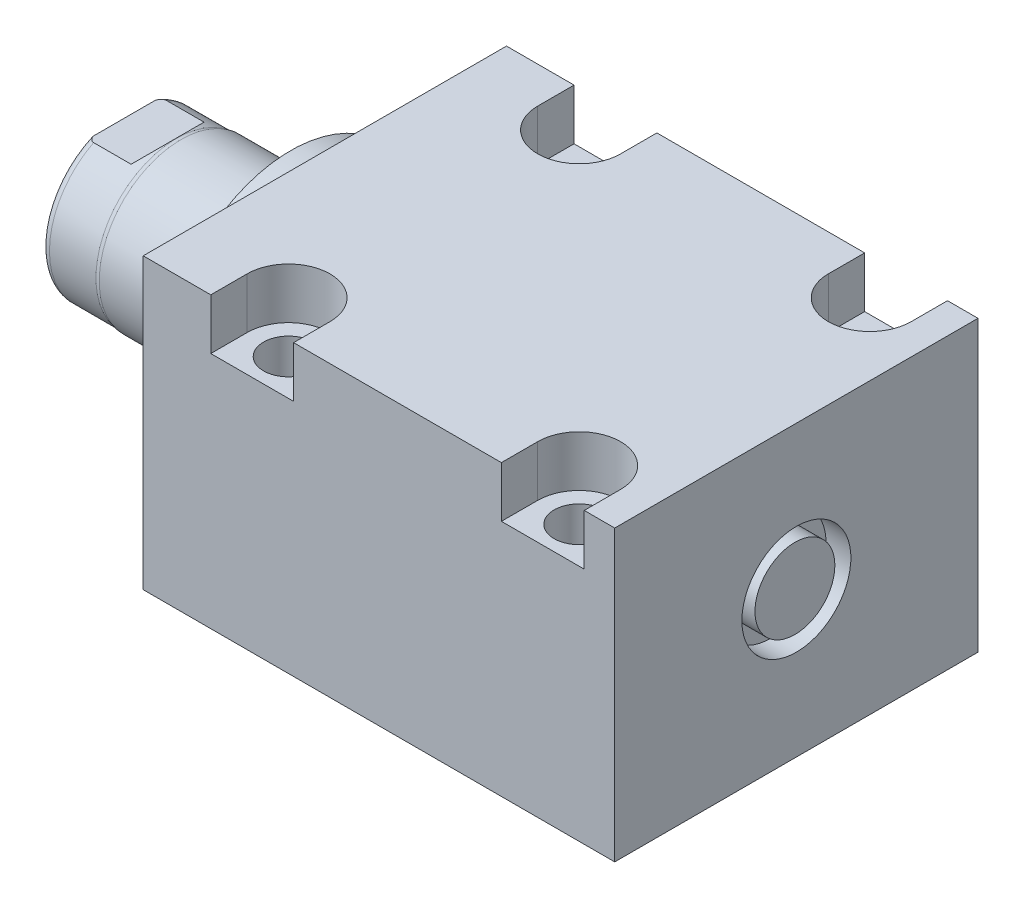
from build123d import *

# Parameters (mm, degrees)
SKETCH1_W          = 63.5
SKETCH1_H          = 50.546
EXTRUDE1_DEPTH     = 82.42
SKETCH5_R          = 22.225
EXTRUDE2_DEPTH     = 5.969
SKETCH6_W          = 14.2875
SKETCH6_H          = 29.091
CUT_EXTRUDE4_DEPTH = 30.48
HOLE2_D            = 8.7376
HOLE2_DEPTH        = 50.546
LPATTERN1_COUNT    = 2
LPATTERN1_PITCH    = 50.8
CUT_EXTRUDE5_DEPTH = 8.89
HOLE3_D            = 3.175
HOLE3_DEPTH        = 9.525
HOLE3_CBORE_D      = 11.3411
HOLE3_CBORE_DEPTH  = 1.4478
HOLE3_TIP          = 0.953866233
HOLE4_D            = 3.175
HOLE4_DEPTH        = 9.525
HOLE4_CBORE_D      = 11.3411
HOLE4_CBORE_DEPTH  = 1.4478
HOLE4_TIP          = 0.953866233
CHAMFER1_SIZE      = 0.635
SKETCH23_R         = 1.4478
LPATTERN3_COUNT    = 2
LPATTERN3_PITCH    = 50.8
SKETCH24_W         = 4.318
SKETCH24_H         = 9.525
SKETCH25_R         = 6.985
EXTRUDE3_DEPTH     = 4.064


with BuildPart() as part:
    # Sketch1 → Extrude1 (new body)
    with BuildSketch(Plane(origin=(0, 0, 0), x_dir=(0, 0, -1), z_dir=(1, 0, 0))):
        with Locations((0, -0.127)):
            Rectangle(SKETCH1_W, SKETCH1_H)
    extrude(amount=EXTRUDE1_DEPTH)

    # Sketch5 → Extrude2 (add)
    with BuildSketch(Plane.ZY):
        with Locations(Location((0, 0, 0), (0, 0, 180))):  # turned: the seam where the file's is
            Circle(SKETCH5_R)
    extrude(amount=EXTRUDE2_DEPTH)

    # Sketch6 → Revolve1 (revolve)
    with BuildSketch(Plane(origin=(0, 0, 0), x_dir=(0, 0, 1), z_dir=(0, -1, 0))):
        with Locations((-7.14375, 20.5145)):
            Rectangle(SKETCH6_W, SKETCH6_H)
    revolve(axis=Axis((5.754582971, 0, 0), (-1, 0, 0)))

    # S2D0001 → Cut-Revolve4 (revolve, cut)
    with BuildSketch(Plane(origin=(-18.511260017, 3.2639, 0), x_dir=(0, 1, 0), z_dir=(0, 0, 1)), mode=Mode.PRIVATE) as cut_revolve4_sk:
        Polygon((2.286, 14.481017728), (2.286, -1.942460017), (-3.2639, -1.942460017), (-3.2639, 16.548739983), (3.4798, 16.548739983), align=None)
    revolve(cut_revolve4_sk.sketch.rotate(Axis((0, 0, 0), (-1, 0, 0)), 90), axis=Axis((0, 0, 0), (-1, 0, 0)), mode=Mode.SUBTRACT)  # turned: the seam where the file's is

    # Sketch8 → Cut-Revolve5 (revolve, cut)
    with BuildSketch(Plane(origin=(0, 0, 0), x_dir=(0, 0, -1), z_dir=(0, 1, 0)), mode=Mode.PRIVATE) as cut_revolve5_sk:
        with BuildLine():
            Line((-14.2875, 25.154), (-14.097, 25.916))
            Line((-14.097, 25.916), (-14.097, 34.044))
            ThreePointArc((-14.097, 34.044), (-13.996678675, 34.587796865), (-13.708922533, 35.06))
            Line((-13.708922533, 35.06), (-14.2875, 35.06))
            Line((-14.2875, 35.06), (-14.2875, 25.154))
        make_face()
    revolve(cut_revolve5_sk.sketch.rotate(Axis((-12.65936, 0, 0), (-1, 0, 0)), 180), axis=Axis((-12.65936, 0, 0), (-1, 0, 0)), mode=Mode.SUBTRACT)  # turned: the seam where the file's is

    # Sketch12 → Cut-Extrude4 (cut, symmetric)
    with BuildSketch(Plane(origin=(0, 0, 0), x_dir=(0, -1, 0), z_dir=(0, 0, -1))):
        Polygon((12.573, 35.06), (12.573, 27.4908), (14.097, 25.9668), (14.097, 35.06), align=None)
        Polygon((-12.573, 35.06), (-12.573, 27.4908), (-14.097, 25.9668), (-14.097, 35.06), align=None)
    extrude(amount=CUT_EXTRUDE4_DEPTH, both=True, mode=Mode.SUBTRACT)

    # Hole2
    with Locations(Plane(origin=(0, 25.146, 0), x_dir=(-1, 0, 0), z_dir=(0, 1, 0))):
        with Locations((-19.05, -25.4), (-19.05, 25.4)):
            hole2 = Hole(HOLE2_D / 2, depth=HOLE2_DEPTH)

    # LPattern1: Hole2 ×2
    with Locations(*[(i * LPATTERN1_PITCH, 0, 0) for i in range(1, LPATTERN1_COUNT)]):
        add(hole2, mode=Mode.SUBTRACT)

    # Sketch18 → Cut-Extrude5 (cut)
    with BuildSketch(Plane(origin=(0, 25.146, 0), x_dir=(1, 0, 0), z_dir=(0, 1, 0))):
        with BuildLine():
            Line((77.089, -31.75), (62.611, -31.75))
            Line((62.611, -31.75), (62.611, -25.4))
            ThreePointArc((62.611, -25.4), (69.85, -18.161), (77.089, -25.4))
            Line((77.089, -25.4), (77.089, -31.75))
        make_face()
        with BuildLine():
            Line((11.811, -25.4), (11.811, -31.75))
            Line((11.811, -31.75), (26.289, -31.75))
            Line((26.289, -31.75), (26.289, -25.4))
            ThreePointArc((26.289, -25.4), (19.05, -18.161), (11.811, -25.4))
        make_face()
        with BuildLine():
            Line((77.089, 25.4), (77.089, 31.75))
            Line((77.089, 31.75), (62.611, 31.75))
            Line((62.611, 31.75), (62.611, 25.4))
            ThreePointArc((62.611, 25.4), (69.85, 18.161), (77.089, 25.4))
        make_face()
        with BuildLine():
            Line((26.289, 31.75), (11.811, 31.75))
            Line((11.811, 31.75), (11.811, 25.4))
            ThreePointArc((11.811, 25.4), (19.05, 18.161), (26.289, 25.4))
            Line((26.289, 25.4), (26.289, 31.75))
        make_face()
    extrude(amount=-CUT_EXTRUDE5_DEPTH, mode=Mode.SUBTRACT)

    # Hole3
    with Locations(Plane.XZ.offset(25.4)):
        with Locations((12.7, 0)):
            CounterBoreHole(HOLE3_D / 2, HOLE3_CBORE_D / 2, HOLE3_CBORE_DEPTH, depth=HOLE3_DEPTH)
            with Locations((0, 0, -(HOLE3_DEPTH + HOLE3_TIP / 2))):  # 118° drill point
                Cone(0, HOLE3_D / 2, HOLE3_TIP, mode=Mode.SUBTRACT)

    # Hole4
    with Locations(Plane.XZ.offset(25.4)):
        with Locations((63.5, 0)):
            CounterBoreHole(HOLE4_D / 2, HOLE4_CBORE_D / 2, HOLE4_CBORE_DEPTH, depth=HOLE4_DEPTH)
            with Locations((0, 0, -(HOLE4_DEPTH + HOLE4_TIP / 2))):  # 118° drill point
                Cone(0, HOLE4_D / 2, HOLE4_TIP, mode=Mode.SUBTRACT)

    # Chamfer1
    chamfer1_edges = [part.edges().sort_by_distance(p)[0] for p in [
        (14.2875, -23.9522, 0),
        (65.0875, -23.9522, 0),
    ]]
    chamfer(chamfer1_edges, length=CHAMFER1_SIZE)

    # Sketch24 → Cut-Revolve6 (revolve, cut)
    with BuildSketch(Plane.XY, mode=Mode.PRIVATE) as cut_revolve6_sk:
        with Locations((80.261, 4.7625)):
            Rectangle(SKETCH24_W, SKETCH24_H)
    revolve(cut_revolve6_sk.sketch.rotate(Axis((0, 0, 0), (1, 0, 0)), 270), axis=Axis((0, 0, 0), (1, 0, 0)), mode=Mode.SUBTRACT)  # turned: the seam where the file's is

    # Sketch25 → Extrude3 (add)
    with BuildSketch(Plane(origin=(78.102, 0, 0), x_dir=(0, 0, -1), z_dir=(1, 0, 0))):
        Circle(SKETCH25_R)
    extrude(amount=EXTRUDE3_DEPTH)


with BuildPart() as body_2:
    # Sketch23 → Revolve2 (revolve)
    with BuildSketch(Plane.XY, mode=Mode.PRIVATE) as revolve2_sk:
        with Locations((8.47725, -25.4)):
            Circle(SKETCH23_R)
    revolve(revolve2_sk.sketch.rotate(Axis((12.7, -23.9522, 0), (0, 1, 0)), 270), axis=Axis((12.7, -23.9522, 0), (0, 1, 0)))  # turned: the seam where the file's is


with BuildPart() as lpattern3_1:
    # LPattern3: pattern copy
    add(body_2.part.moved(Location(Vector(1, 0, 0) * (1 * LPATTERN3_PITCH))))


solid = Compound([part.part, body_2.part, lpattern3_1.part])
